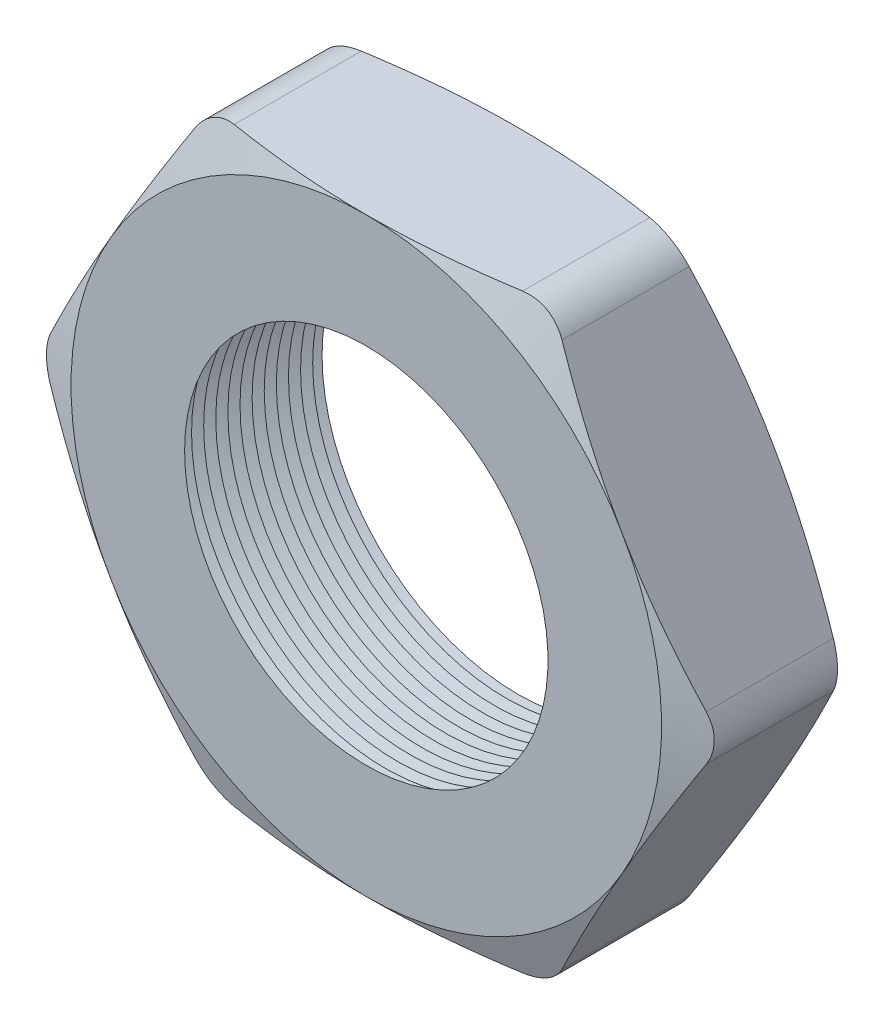
from build123d import *

# Parameters (mm, degrees)
SKETCH1_R          = 3.048
EXTRUDE1_DEPTH     = 2.54
FILLET1_R          = 0.762
SKETCH2_OUTSIDE_W  = 35.688
SKETCH2_OUTSIDE_H  = 34.392
SKETCH2_OUTSIDE_R  = 4.953
CUT_EXTRUDE1_DEPTH = 3.54
CUT_EXTRUDE1_DRAFT = -70
SKETCH3_OUTSIDE_W  = 35.688
SKETCH3_OUTSIDE_H  = 34.392
SKETCH3_OUTSIDE_R  = 4.953
CUT_EXTRUDE2_DEPTH = 3.5400001
CUT_EXTRUDE2_DRAFT = -70
LPATTERN1_COUNT    = 13
LPATTERN1_PITCH    = 0.2032


with BuildPart() as part:
    # Sketch1 → Extrude1 (new body)
    with BuildSketch(Plane.XY):
        Polygon((-5.719231767, 0), (-2.859615883, -4.953), (2.859615883, -4.953), (5.719231767, 0), (2.859615883, 4.953), (-2.859615883, 4.953), align=None)
        Circle(SKETCH1_R, mode=Mode.SUBTRACT)
    extrude(amount=EXTRUDE1_DEPTH)

    # Fillet1
    fillet1_edges = [part.edges().sort_by_distance(p)[0] for p in [
        (5.719231767, 0, 1.27),
        (2.859615883, -4.953, 1.27),
        (-2.859615883, -4.953, 1.27),
        (-5.719231767, 0, 1.27),
        (-2.859615883, 4.953, 1.27),
        (2.859615883, 4.953, 1.27),
    ]]
    fillet(fillet1_edges, radius=FILLET1_R)


with BuildPart() as cut_extrude1_tool:
    # Sketch2 outside → Cut-Extrude1 (with draft: the straight prism first)
    with BuildSketch(Plane.XY.offset(2.54)):
        Rectangle(SKETCH2_OUTSIDE_W, SKETCH2_OUTSIDE_H)
        Circle(SKETCH2_OUTSIDE_R, mode=Mode.SUBTRACT)
    extrude(amount=-CUT_EXTRUDE1_DEPTH)
    # Cut-Extrude1: the draft: its side faces are tilted about the plane it starts from
    cut_extrude1_sides = [cut_extrude1_tool.faces().sort_by_distance(p)[0] for p in [
        (0, -17.196, 0.77),
        (17.844, 0, 0.77),
        (0, 17.196, 0.77),
        (-17.844, 0, 0.77),
        (-4.953, 0, 0.77),
    ]]
    draft(cut_extrude1_sides, Plane.XY.offset(2.54), CUT_EXTRUDE1_DRAFT)


with BuildPart() as part_1:
    add(part.part)

    # Cut-Extrude1: cut by cut_extrude1_tool
    add(cut_extrude1_tool.part, mode=Mode.SUBTRACT)


with BuildPart() as cut_extrude2_tool:
    # Sketch3 outside → Cut-Extrude2 (with draft: the straight prism first)
    with BuildSketch(Plane(origin=(0, 0, 0), x_dir=(-1, 0, 0), z_dir=(0, 0, -1))):
        Rectangle(SKETCH3_OUTSIDE_W, SKETCH3_OUTSIDE_H)
        Circle(SKETCH3_OUTSIDE_R, mode=Mode.SUBTRACT)
    extrude(amount=-CUT_EXTRUDE2_DEPTH)
    # Cut-Extrude2: the draft: its side faces are tilted about the plane it starts from
    cut_extrude2_sides = [cut_extrude2_tool.faces().sort_by_distance(p)[0] for p in [
        (0, -17.196, 1.77000005),
        (-17.844, 0, 1.77000005),
        (0, 17.196, 1.77000005),
        (17.844, 0, 1.77000005),
        (4.953, 0, 1.77000005),
    ]]
    draft(cut_extrude2_sides, Plane(origin=(0, 0, 0), x_dir=(-1, 0, 0), z_dir=(0, 0, -1)), CUT_EXTRUDE2_DRAFT)


with BuildPart() as part_2:
    add(part_1.part)

    # Cut-Extrude2: cut by cut_extrude2_tool
    add(cut_extrude2_tool.part, mode=Mode.SUBTRACT)

    # Sketch4 → Cut-Revolve1 (revolve, cut)
    with BuildSketch(Plane(origin=(0, 0, 0), x_dir=(1, 0, 0), z_dir=(0, 1, 0))):
        Polygon((-3.048, -2.54), (-3.048, -2.100059095), (-3.429, -2.320029547), align=None)
    cut_revolve1 = revolve(axis=Axis((0, 0, 2.54), (0, 0, -1)), mode=Mode.SUBTRACT)

    # LPattern1: Cut-Revolve1 ×13
    with Locations(*[(0, 0, -i * LPATTERN1_PITCH) for i in range(1, LPATTERN1_COUNT)]):
        add(cut_revolve1, mode=Mode.SUBTRACT)


solid = part_2.part
